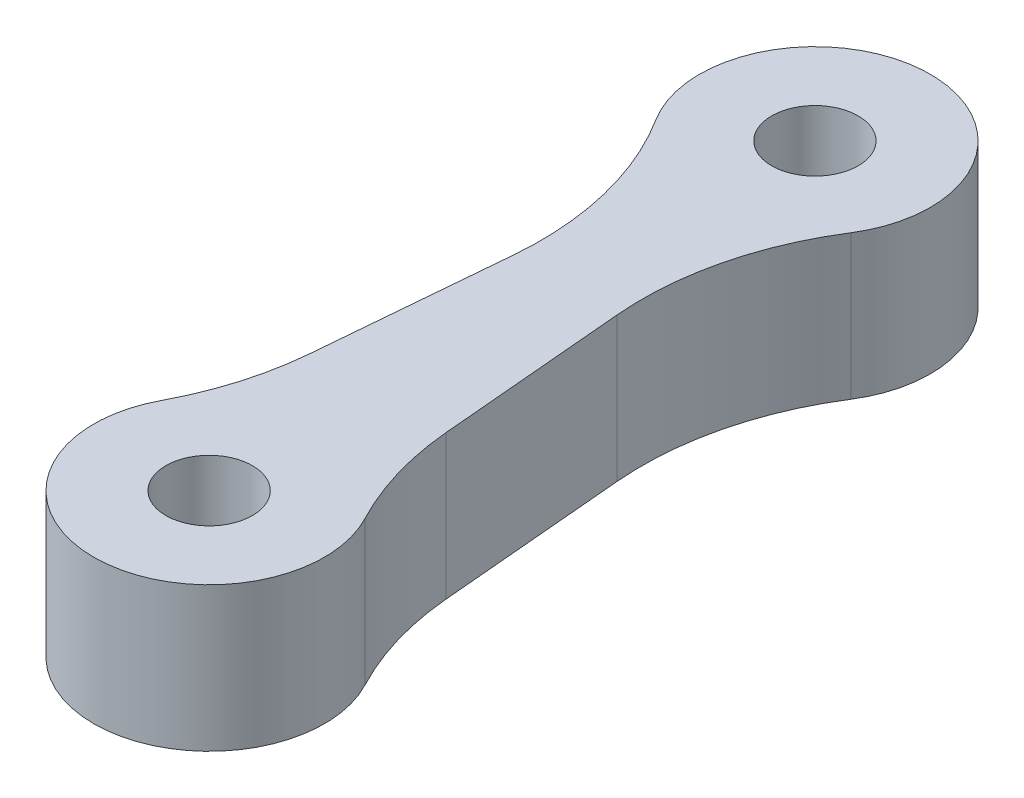
from build123d import *

# Parameters (mm, degrees)
SKETCH_1_R      = 3
EXTRUDE_1_DEPTH = 10


with BuildPart() as part:
    # Эскиз1 → Бобышка-Вытянуть1 (new body)
    with BuildSketch(Plane(origin=(0, 0, 0), x_dir=(1, 0, 0), z_dir=(0, 1, 0))):
        with BuildLine():
            ThreePointArc((-7.075672476, -38.267057593), (0, -50), (7.075672476, -38.267057593))
            ThreePointArc((7.075672476, -38.267057593), (5.504494197, -34.399886744), (4.729224066, -30.298354373))
            Line((4.729224066, -30.298354373), (3.594110581, -17.323947875))
            ThreePointArc((3.594110581, -17.323947875), (4.107078394, -10.538940279), (6.762537722, -4.27411787))
            ThreePointArc((6.762537722, -4.27411787), (0, 8), (-6.762537722, -4.27411787))
            ThreePointArc((-6.762537722, -4.27411787), (-4.107078394, -10.538940279), (-3.594110581, -17.323947875))
            Line((-3.594110581, -17.323947875), (-4.729224066, -30.298354373))
            ThreePointArc((-4.729224066, -30.298354373), (-5.504494197, -34.399886744), (-7.075672476, -38.267057593))
        make_face()
        with Locations((0, -42)):
            Circle(SKETCH_1_R, mode=Mode.SUBTRACT)
        Circle(SKETCH_1_R, mode=Mode.SUBTRACT)
    extrude(amount=EXTRUDE_1_DEPTH)


solid = part.part
